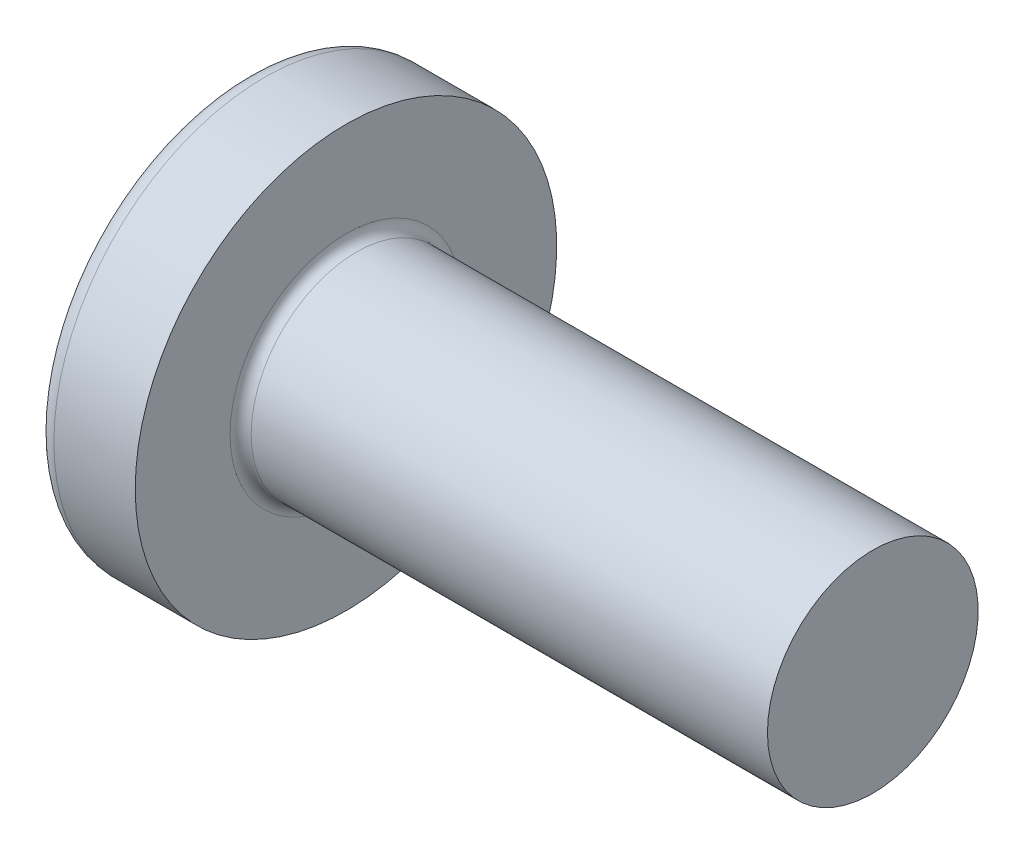
from build123d import *

# Parameters (mm, degrees)
FILLET1_R    = 0.2
SKETCH3_W    = 1.03
SKETCH3_H    = 4.3
SKETCH4_W    = 1.03
SKETCH4_H    = 1.966638464
RECPAT_COUNT = 2
RECPAT_ANGLE = 90


with BuildPart() as part:
    # BodySke → Base-Revolve (revolve)
    with BuildSketch(Plane.XY):
        with BuildLine():
            Line((3.1, 2), (3.1, 4))
            Line((3.1, 4), (1.555305874, 4))
            ThreePointArc((1.555305874, 4), (1.392873227, 3.961271902), (1.265388955, 3.853420195))
            ThreePointArc((1.265388955, 3.853420195), (0.324444487, 2.027933456), (0, 0))
            Line((0, 0), (13.1, 0))
            Line((13.1, 0), (13.1, 2))
            Line((13.1, 2), (3.1, 2))
        make_face()
    revolve(axis=Axis((-25.4, 0, 0), (1, 0, 0)))

    # Fillet1
    fillet1_edges = [part.edges().sort_by_distance(p)[0] for p in [
        (3.1, -2, 0),
    ]]
    fillet(fillet1_edges, radius=FILLET1_R)

    # Sketch3 → Recess section 0
    with BuildSketch(Plane(origin=(0, 0, 0), x_dir=(0, 0, -1), z_dir=(1, 0, 0))):
        Rectangle(SKETCH3_W, SKETCH3_H)
    # Sketch4 → Recess section 1
    with BuildSketch(Plane(origin=(2.34, 0, 0), x_dir=(0, 0, -1), z_dir=(1, 0, 0))):
        Rectangle(SKETCH4_W, SKETCH4_H)
    recess = loft(mode=Mode.SUBTRACT)

    # RecPat: Recess ×2 about axis
    recpat_axis = Axis((0, 0, 0), (1, 0, 0))
    for i in range(1, RECPAT_COUNT):
        add(recess.rotate(recpat_axis, i * RECPAT_ANGLE / (RECPAT_COUNT - 1)), mode=Mode.SUBTRACT)

    # RecCorSke → RecessCore (revolve, cut)
    with BuildSketch(Plane.XY):
        Polygon((0, 0), (0, 1.01462874), (2.34, 0.851), (2.616506661, 0), align=None)
    revolve(axis=Axis((-3.175, 0, 0), (1, 0, 0)), mode=Mode.SUBTRACT)


solid = part.part
